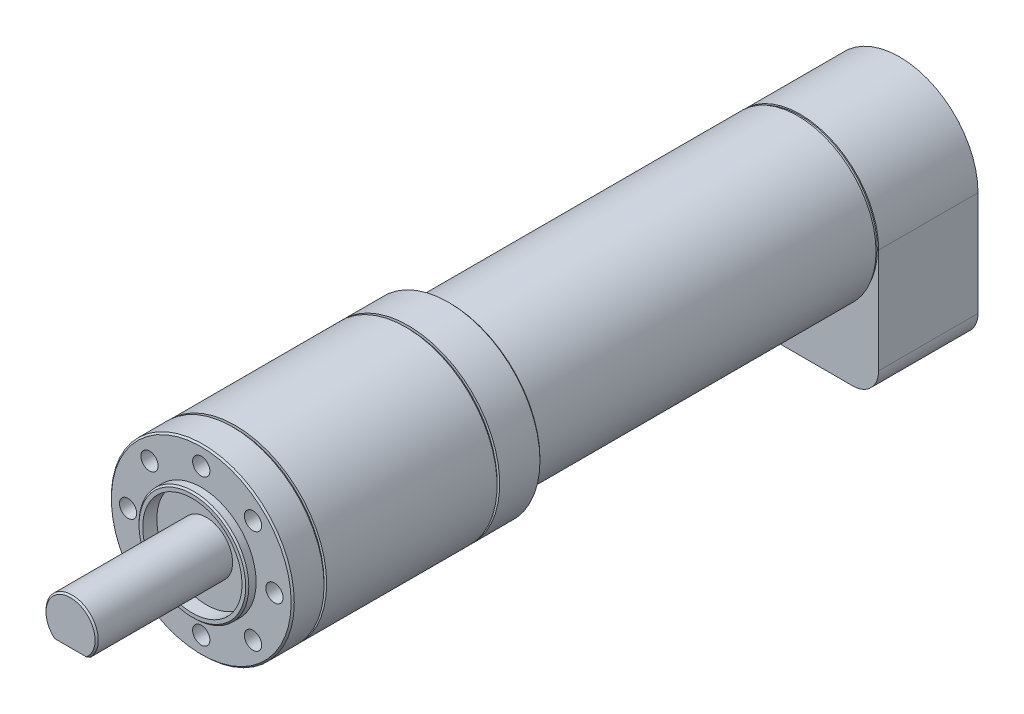
from build123d import *

# Parameters (mm, degrees)
SKETCH_1_R             = 17.5
EXTRUDE_1_DEPTH        = 47.6
SKETCH_2_R             = 9.5
CUT_EXTRUDE_1_DEPTH    = 1
SKETCH_3_R             = 10.5
SKETCH_3_R_2           = 9.5
EXTRUDE_2_DEPTH        = 1.7
SKETCH_4_R             = 5
EXTRUDE_3_DEPTH        = 26
CUT_EXTRUDE_2_DEPTH    = 20
SKETCH_12_R            = 15
EXTRUDE_4_DEPTH        = 67
EXTRUDE_5_DEPTH        = 19
HOLE_WIZARD_M4_6_D     = 3.3
HOLE_WIZARD_M4_6_DEPTH = 8
HOLE_WIZARD_M4_6_TIP   = 0.991420021
SKETCH_18_R            = 17.5
SKETCH_18_R_2          = 17
CUT_EXTRUDE_5_DEPTH    = 0.5
SKETCH_19_R            = 17.5
SKETCH_19_R_2          = 17
CUT_EXTRUDE_6_DEPTH    = 0.5
SKETCH_20_R            = 15
SKETCH_20_R_2          = 14.75
CUT_EXTRUDE_7_DEPTH    = 0.5
CHAMFER_1_SIZE         = 0.3
CHAMFER_2_SIZE         = 0.3
FILLET_1_R             = 5


with BuildPart() as part:
    # 草图1 → 凸台-拉伸1 (new body)
    with BuildSketch(Plane.XY):
        Circle(SKETCH_1_R)
    extrude(amount=EXTRUDE_1_DEPTH)

    # 草图2 → 切除-拉伸1 (cut)
    with BuildSketch(Plane.XY.offset(47.6)):
        Circle(SKETCH_2_R)
    extrude(amount=-CUT_EXTRUDE_1_DEPTH, mode=Mode.SUBTRACT)

    # 草图3 → 凸台-拉伸2 (add)
    with BuildSketch(Plane.XY.offset(47.6)):
        Circle(SKETCH_3_R)
        Circle(SKETCH_3_R_2, mode=Mode.SUBTRACT)
    extrude(amount=EXTRUDE_2_DEPTH)

    # 草图4 → 凸台-拉伸3 (add)
    with BuildSketch(Plane.XY.offset(46.6)):
        Circle(SKETCH_4_R)
    extrude(amount=EXTRUDE_3_DEPTH)

    # 草图5 → 切除-拉伸2 (cut)
    with BuildSketch(Plane.XY.offset(72.6)):
        with BuildLine():
            Line((-3.469870315, -3.6), (3.469870315, -3.6))
            ThreePointArc((3.469870315, -3.6), (0, -5), (-3.469870315, -3.6))
        make_face()
    extrude(amount=-CUT_EXTRUDE_2_DEPTH, mode=Mode.SUBTRACT)

    # 草图12 → 凸台-拉伸4 (add)
    with BuildSketch(Plane(origin=(0, 0, 0), x_dir=(-1, 0, 0), z_dir=(0, 0, -1))):
        Circle(SKETCH_12_R)
    extrude(amount=EXTRUDE_4_DEPTH)

    # 草图15 → 凸台-拉伸5 (add)
    with BuildSketch(Plane(origin=(0, 0, -67), x_dir=(-1, 0, 0), z_dir=(0, 0, -1))):
        with BuildLine():
            Line((-15, 0), (-15, -25))
            Line((-15, -25), (15, -25))
            Line((15, -25), (15, 0))
            ThreePointArc((15, 0), (0, 15), (-15, 0))
        make_face()
    extrude(amount=EXTRUDE_5_DEPTH)

    # M4 螺纹孔6
    with Locations(Plane(origin=(0, 14, 47.6), x_dir=(1, 0, 0), z_dir=(0, 0, 1))):
        with Locations((0, 0), (-9.899494937, -4.100505063), (-14, -14), (-9.899494937, -23.899494937), (0, -28), (9.899494937, -23.899494937), (14, -14), (9.899494937, -4.100505063)):
            Hole(HOLE_WIZARD_M4_6_D / 2, depth=HOLE_WIZARD_M4_6_DEPTH)
            with Locations((0, 0, -(HOLE_WIZARD_M4_6_DEPTH + HOLE_WIZARD_M4_6_TIP / 2))):  # 118° drill point
                Cone(0, HOLE_WIZARD_M4_6_D / 2, HOLE_WIZARD_M4_6_TIP, mode=Mode.SUBTRACT)

    # 草图18 → 切除-拉伸5 (cut)
    with BuildSketch(Plane.XY.offset(41.6)):
        Circle(SKETCH_18_R)
        Circle(SKETCH_18_R_2, mode=Mode.SUBTRACT)
    extrude(amount=-CUT_EXTRUDE_5_DEPTH, mode=Mode.SUBTRACT)

    # 草图19 → 切除-拉伸6 (cut)
    with BuildSketch(Plane(origin=(0, 0, 8), x_dir=(-1, 0, 0), z_dir=(0, 0, -1))):
        Circle(SKETCH_19_R)
        Circle(SKETCH_19_R_2, mode=Mode.SUBTRACT)
    extrude(amount=-CUT_EXTRUDE_6_DEPTH, mode=Mode.SUBTRACT)

    # 草图20 → 切除-拉伸7 (cut)
    with BuildSketch(Plane.XY.offset(-67)):
        Circle(SKETCH_20_R)
        Circle(SKETCH_20_R_2, mode=Mode.SUBTRACT)
    extrude(amount=CUT_EXTRUDE_7_DEPTH, mode=Mode.SUBTRACT)

    # 倒角1
    chamfer_1_edges = [part.edges().sort_by_distance(p)[0] for p in [
        (-17.5, 0, 0),
        (-1.955843607, 4.601594918, 72.6),
        (-17.5, 0, 47.6),
    ]]
    chamfer(chamfer_1_edges, length=CHAMFER_1_SIZE)

    # 倒角2
    chamfer_2_edges = [part.edges().sort_by_distance(p)[0] for p in [
        (-10.5, 0, 49.3),
    ]]
    chamfer(chamfer_2_edges, length=CHAMFER_2_SIZE)

    # 圆角1
    fillet_1_edges = [part.edges().sort_by_distance(p)[0] for p in [
        (15, -25, -76.5),
        (-15, -25, -76.5),
    ]]
    fillet(fillet_1_edges, radius=FILLET_1_R)


solid = part.part
